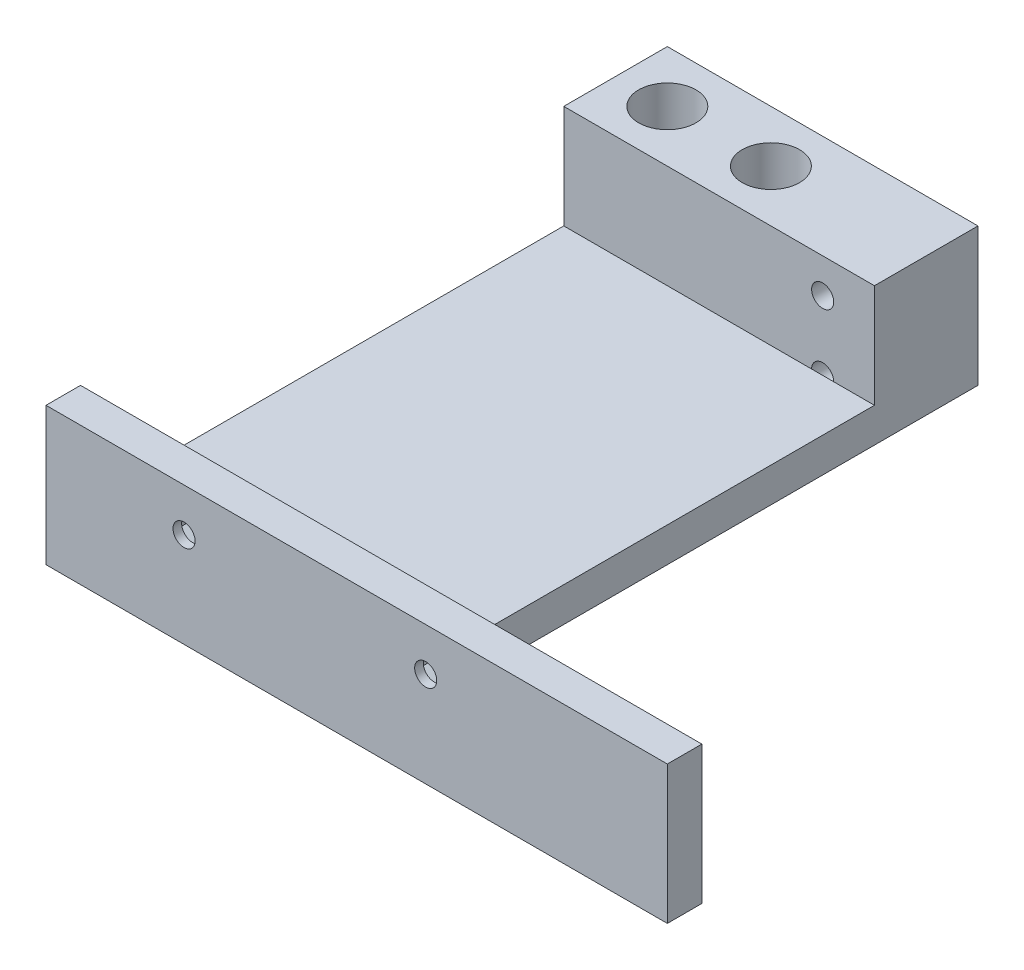
from build123d import *

# Parameters (mm, degrees)
SKETCH2_W           = 15
SKETCH2_H           = 15
SKETCH2_W_2         = 30
SKETCH2_R           = 4.15
BOSS_EXTRUDE1_DEPTH = 10
SKETCH2_3_W         = 15
SKETCH2_3_H         = 15
SKETCH2_3_W_2       = 30
SKETCH2_3_R         = 4.15
BOSS_EXTRUDE2_DEPTH = 10
SKETCH4_R           = 1.6
CUT_EXTRUDE1_DEPTH  = 36
CUT_EXTRUDE2_START  = -6.25
SKETCH4_3_R         = 1.6
CUT_EXTRUDE2_DEPTH  = 2.5
SKETCH5_W           = 45
SKETCH5_H           = 5
BOSS_EXTRUDE3_DEPTH = 75
SKETCH6_W           = 45
SKETCH6_H           = 5
BOSS_EXTRUDE4_DEPTH = 15
SKETCH7_W           = 5
SKETCH7_H           = 20
BOSS_EXTRUDE5_DEPTH = 45
CUT_EXTRUDE3_REACH  = 119.58
SKETCH8_R           = 1.6
CUT_EXTRUDE4_START  = -1.25
CUT_EXTRUDE4_DEPTH  = 2.5


with BuildPart() as part:
    # Sketch2 → Boss-Extrude1 (new body)
    with BuildSketch(Plane(origin=(0, 0, 0), x_dir=(1, 0, 0), z_dir=(0, 1, 0))):
        with Locations((22.5, 0)):
            Rectangle(SKETCH2_W, SKETCH2_H)
        Rectangle(SKETCH2_W_2, SKETCH2_H)
        with Locations(Location((7.5, 0, 0), (0, 0, 270))):
            Circle(SKETCH2_R, mode=Mode.SUBTRACT)
        with Locations(Location((-7.5, 0, 0), (0, 0, 270))):
            Circle(SKETCH2_R, mode=Mode.SUBTRACT)
    extrude(amount=BOSS_EXTRUDE1_DEPTH)

    # Sketch2_3 → Boss-Extrude2 (add)
    with BuildSketch(Plane(origin=(0, 0, 0), x_dir=(1, 0, 0), z_dir=(0, 1, 0))):
        with Locations((22.5, 0)):
            Rectangle(SKETCH2_3_W, SKETCH2_3_H)
        Rectangle(SKETCH2_3_W_2, SKETCH2_3_H)
        with Locations(Location((7.5, 0, 0), (0, 0, 270))):
            Circle(SKETCH2_3_R, mode=Mode.SUBTRACT)
        with Locations(Location((-7.5, 0, 0), (0, 0, 270))):
            Circle(SKETCH2_3_R, mode=Mode.SUBTRACT)
        with Locations(Location((-7.5, 0, 0), (0, 0, 270))):
            Circle(SKETCH2_3_R)
        with Locations(Location((7.5, 0, 0), (0, 0, 270))):
            Circle(SKETCH2_3_R)
    extrude(amount=-BOSS_EXTRUDE2_DEPTH)

    # Sketch4 → Cut-Extrude1 (cut, through all)
    with BuildSketch(Plane.XY.offset(7.5)):
        with Locations((22.5, 5)):
            Circle(SKETCH4_R)
        with Locations((22.5, -5)):
            Circle(SKETCH4_R)
    extrude(amount=-CUT_EXTRUDE1_DEPTH, mode=Mode.SUBTRACT)

    # Sketch4_3 → Cut-Extrude2 (cut)
    with BuildSketch(Plane.XY.offset(7.5).offset(CUT_EXTRUDE2_START)):
        Polygon((22.5, 8.435234102), (19.525, 6.717617051), (19.525, 3.282382949), (22.5, 1.564765898), (25.475, 3.282382949), (25.475, 6.717617051), align=None)
        with Locations((22.5, 5)):
            Circle(SKETCH4_3_R, mode=Mode.SUBTRACT)
        Polygon((22.5, -8.435234102), (25.475, -6.717617051), (25.475, -3.282382949), (22.5, -1.564765898), (19.525, -3.282382949), (19.525, -6.717617051), align=None)
        with Locations((22.5, -5)):
            Circle(SKETCH4_3_R, mode=Mode.SUBTRACT)
    extrude(amount=-CUT_EXTRUDE2_DEPTH, mode=Mode.SUBTRACT)

    # Sketch5 → Boss-Extrude3 (add)
    with BuildSketch(Plane.XY.offset(7.5)):
        with Locations((7.5, -7.5)):
            Rectangle(SKETCH5_W, SKETCH5_H)
    extrude(amount=BOSS_EXTRUDE3_DEPTH)

    # Sketch6 → Boss-Extrude4 (add)
    with BuildSketch(Plane(origin=(0, -5, 0), x_dir=(1, 0, 0), z_dir=(0, 1, 0))):
        with Locations((7.5, -80)):
            Rectangle(SKETCH6_W, SKETCH6_H)
    extrude(amount=BOSS_EXTRUDE4_DEPTH)

    # Sketch7 → Boss-Extrude5 (add)
    with BuildSketch(Plane(origin=(30, 0, 0), x_dir=(0, 0, -1), z_dir=(1, 0, 0))):
        with Locations((-80, 0)):
            Rectangle(SKETCH7_W, SKETCH7_H)
    extrude(amount=BOSS_EXTRUDE5_DEPTH)

    # Sketch8 → Cut-Extrude3 (cut, up to next)
    with BuildSketch(Plane.XY.offset(82.5), mode=Mode.PRIVATE) as cut_extrude3_sk1:
        with Locations((5, 3.75)):
            Circle(SKETCH8_R)
    cut_extrude3_tool1 = extrude(cut_extrude3_sk1.sketch, amount=-CUT_EXTRUDE3_REACH, mode=Mode.PRIVATE) & part.part
    # Sketch8 → Cut-Extrude3 (cut, up to next)
    with BuildSketch(Plane.XY.offset(82.5), mode=Mode.PRIVATE) as cut_extrude3_sk2:
        with Locations((40, 3.75)):
            Circle(SKETCH8_R)
    cut_extrude3_tool2 = extrude(cut_extrude3_sk2.sketch, amount=-CUT_EXTRUDE3_REACH, mode=Mode.PRIVATE) & part.part
    add(cut_extrude3_tool1.solids().sort_by_distance((5, 3.75, 82.5))[0], mode=Mode.SUBTRACT)
    add(cut_extrude3_tool2.solids().sort_by_distance((40, 3.75, 82.5))[0], mode=Mode.SUBTRACT)

    # Sketch9 → Cut-Extrude4 (cut)
    with BuildSketch(Plane.XY.offset(82.5).offset(CUT_EXTRUDE4_START)):
        Polygon((5, 0.314765898), (7.975, 2.032382949), (7.975, 5.467617051), (5, 7.185234102), (2.025, 5.467617051), (2.025, 2.032382949), align=None)
        Polygon((40, 0.314765898), (42.975, 2.032382949), (42.975, 5.467617051), (40, 7.185234102), (37.025, 5.467617051), (37.025, 2.032382949), align=None)
    extrude(amount=-CUT_EXTRUDE4_DEPTH, mode=Mode.SUBTRACT)


solid = part.part
